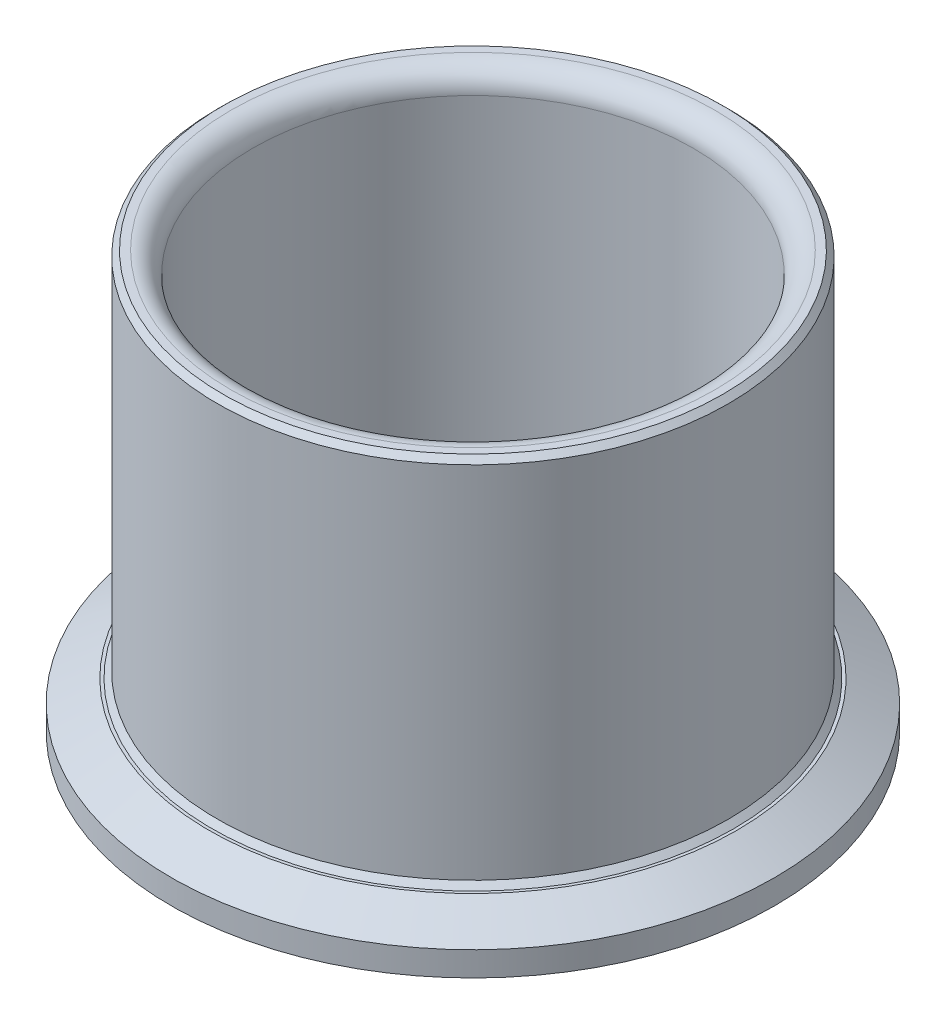
from build123d import *

# Parameters (mm, degrees)
SKETCH3_R          = 30.175
CUT_EXTRUDE1_DEPTH = 59.15
CHAMFER1_SIZE      = 0.75
CHAMFER2_SIZE      = 3
CHAMFER2_SIZE2     = 5.196152423
FILLET1_R          = 3


with BuildPart() as part:
    # Sketch2 → Revolve1 (revolve)
    with BuildSketch(Plane.XY):
        Polygon((0, 0), (0, 58.15), (-35, 58.15), (-35, 7.35), (-41.35, 7.35), (-41.35, 1), (-31.75, 1), (-31.75, 0), align=None)
    revolve(axis=Axis((0, 0, 0), (0, 1, 0)))

    # Sketch3 → Cut-Extrude1 (cut, through all)
    with BuildSketch(Plane(origin=(0, 58.15, 0), x_dir=(1, 0, 0), z_dir=(0, 1, 0))):
        Circle(SKETCH3_R)
    extrude(amount=-CUT_EXTRUDE1_DEPTH, mode=Mode.SUBTRACT)

    # Chamfer1
    chamfer1_edges = [part.edges().sort_by_distance(p)[0] for p in [
        (35, 7.35, 0),
        (35, 58.15, 0),
    ]]
    chamfer(chamfer1_edges, length=CHAMFER1_SIZE)

    # Chamfer2
    chamfer2_edges = [part.edges().sort_by_distance(p)[0] for p in [
        (41.35, 7.35, 0),
    ]]
    chamfer2_side = [part.faces().sort_by_distance(p)[0] for p in [
        (41.35, 4.175, 0),
    ]]
    chamfer(chamfer2_edges, length=CHAMFER2_SIZE, length2=CHAMFER2_SIZE2, reference=chamfer2_side[0])

    # Fillet1
    fillet1_edges = [part.edges().sort_by_distance(p)[0] for p in [
        (-30.175, 58.15, 0),
    ]]
    fillet(fillet1_edges, radius=FILLET1_R)


solid = part.part
